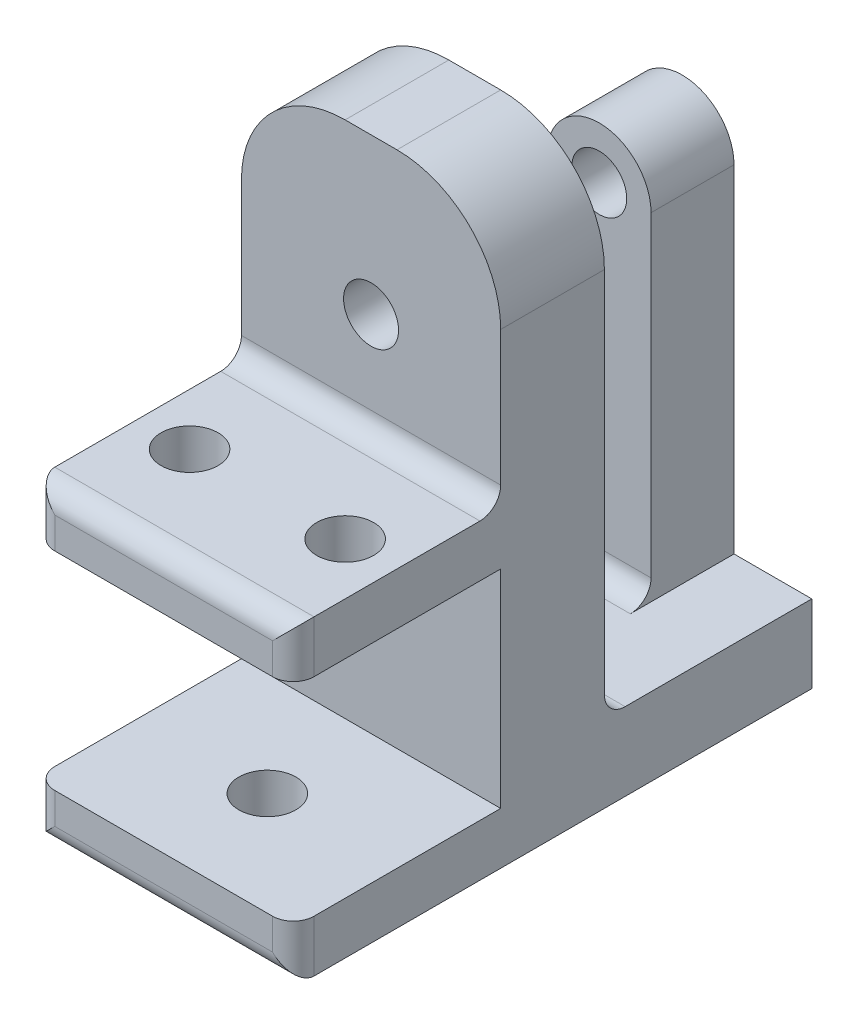
from build123d import *

# Parameters (mm, degrees)
SKETCH1_R           = 2.65
BOSS_EXTRUDE1_DEPTH = 10
BOSS_EXTRUDE2_START = -20
SKETCH2_W           = 25
SKETCH2_H           = 20
BOSS_EXTRUDE2_DEPTH = 5
BOSS_EXTRUDE3_DEPTH = 5
SKETCH4_W           = 25
SKETCH4_H           = 7.5
BOSS_EXTRUDE4_DEPTH = 20
SKETCH5_W           = 10
SKETCH5_H           = 20
BOSS_EXTRUDE5_DEPTH = 8
FILLET2_R           = 2
SKETCH6_R           = 2.75
CUT_EXTRUDE1_DEPTH  = 6
SKETCH7_R           = 2.75
CUT_EXTRUDE2_DEPTH  = 6
BOSS_EXTRUDE6_START = -8
BOSS_EXTRUDE6_DEPTH = 8
SKETCH9_R           = 2.65
CUT_EXTRUDE3_DEPTH  = 50
FILLET4_R           = 2
FILLET6_R           = 2


with BuildPart() as part:
    # Sketch1 → Boss-Extrude1 (new body)
    with BuildSketch(Plane.XY):
        with BuildLine():
            Line((0, 0), (25, 0))
            Line((25, 0), (25, 40))
            ThreePointArc((25, 40), (22.071067812, 47.071067812), (15, 50))
            Line((15, 50), (10, 50))
            ThreePointArc((10, 50), (2.928932188, 47.071067812), (0, 40))
            Line((0, 40), (0, 0))
        make_face()
        with Locations((12.5, 35)):
            Circle(SKETCH1_R, mode=Mode.SUBTRACT)
    extrude(amount=BOSS_EXTRUDE1_DEPTH)

    # Sketch2 → Boss-Extrude2 (add)
    with BuildSketch(Plane.XZ.offset(BOSS_EXTRUDE2_START)):
        with Locations((12.5, 20)):
            Rectangle(SKETCH2_W, SKETCH2_H)
    extrude(amount=-BOSS_EXTRUDE2_DEPTH)

    # Sketch3 → Boss-Extrude3 (add)
    with BuildSketch(Plane.XZ):
        Polygon((0, 0), (25, 0), (25, 10), (25, 30), (0, 30), (0, 10), align=None)
    extrude(amount=BOSS_EXTRUDE3_DEPTH)

    # Sketch4 → Boss-Extrude4 (add)
    with BuildSketch(Plane(origin=(0, 0, 0), x_dir=(-1, 0, 0), z_dir=(0, 0, -1))):
        with Locations((-12.5, -1.25)):
            Rectangle(SKETCH4_W, SKETCH4_H)
    extrude(amount=BOSS_EXTRUDE4_DEPTH)

    # Sketch5 → Boss-Extrude5 (add)
    with BuildSketch(Plane(origin=(0, 0, -20), x_dir=(-1, 0, 0), z_dir=(0, 0, -1))):
        with Locations((-12.5, 12.5)):
            Rectangle(SKETCH5_W, SKETCH5_H)
    extrude(amount=-BOSS_EXTRUDE5_DEPTH)

    # Fillet2
    fillet2_edges = [part.edges().sort_by_distance(p)[0] for p in [
        (12.5, 2.5, 0),
        (12.5, 2.5, -12),
    ]]
    fillet(fillet2_edges, radius=FILLET2_R)

    # Sketch6 → Cut-Extrude1 (cut)
    with BuildSketch(Plane(origin=(0, 25, 0), x_dir=(1, 0, 0), z_dir=(0, 1, 0))):
        with Locations((5, -20)):
            Circle(SKETCH6_R)
        with Locations((20, -20)):
            Circle(SKETCH6_R)
    extrude(amount=-CUT_EXTRUDE1_DEPTH, mode=Mode.SUBTRACT)

    # Sketch7 → Cut-Extrude2 (cut)
    with BuildSketch(Plane.XZ.offset(5)):
        with Locations((12.5, 20)):
            Circle(SKETCH7_R)
    extrude(amount=-CUT_EXTRUDE2_DEPTH, mode=Mode.SUBTRACT)

    # Sketch8 → Boss-Extrude6 (add)
    with BuildSketch(Plane(origin=(0, 0, -20), x_dir=(-1, 0, 0), z_dir=(0, 0, -1)).offset(BOSS_EXTRUDE6_START)):
        with BuildLine():
            Line((-17.5, 22.5), (-17.5, 35))
            ThreePointArc((-17.5, 35), (-12.5, 40), (-7.5, 35))
            Line((-7.5, 35), (-7.5, 22.5))
            Line((-7.5, 22.5), (-17.5, 22.5))
        make_face()
    extrude(amount=BOSS_EXTRUDE6_DEPTH)

    # Sketch9 → Cut-Extrude3 (cut)
    with BuildSketch(Plane(origin=(0, 0, -20), x_dir=(-1, 0, 0), z_dir=(0, 0, -1))):
        with Locations((-12.5, 35)):
            Circle(SKETCH9_R)
    extrude(amount=-CUT_EXTRUDE3_DEPTH, mode=Mode.SUBTRACT)

    # Fillet4
    fillet4_edges = [part.edges().sort_by_distance(p)[0] for p in [
        (12.5, 25, 10),
    ]]
    fillet(fillet4_edges, radius=FILLET4_R)

    # Fillet6
    fillet6_edges = [part.edges().sort_by_distance(p)[0] for p in [
        (12.5, 25, 30),
        (0, 22.5, 30),
        (25, 22.5, 30),
        (25, -2.5, 30),
        (0, -2.5, 30),
        (12.5, -5, 30),
    ]]
    fillet(fillet6_edges, radius=FILLET6_R)


solid = part.part
